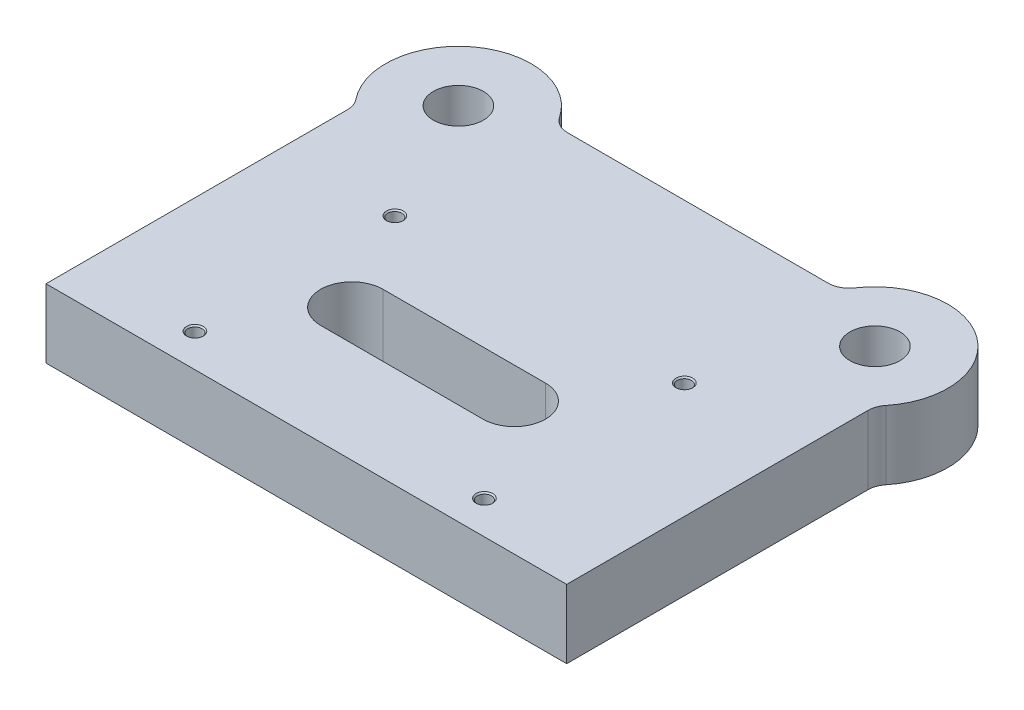
from build123d import *

# Parameters (mm, degrees)
SKETCH1_R                   = 12
BOSS_EXTRUDE1_DEPTH         = 33
FILLET1_R                   = 10
M8_TAPPED_HOLE1_D           = 6.8
M8_TAPPED_HOLE1_DEPTH       = 33
M8_TAPPED_HOLE1_CSINK_D     = 8.05
M8_TAPPED_HOLE1_CSINK_ANGLE = 90
CUT_EXTRUDE1_REACH          = 35


with BuildPart() as part:
    # Sketch1 → Boss-Extrude1 (new body)
    with BuildSketch(Plane(origin=(0, 0, 0), x_dir=(1, 0, 0), z_dir=(0, 1, 0))):
        with BuildLine():
            Line((125, 0), (-125, 0))
            Line((-125, 0), (-125, 148.505102572))
            ThreePointArc((-125, 148.505102572), (-120.023162168, 201.706671295), (-68.377223398, 188))
            Line((-68.377223398, 188), (68.377223398, 188))
            ThreePointArc((68.377223398, 188), (120.023162168, 201.706671295), (125, 148.505102572))
            Line((125, 148.505102572), (125, 0))
        make_face()
        with Locations((-100, 173)):
            Circle(SKETCH1_R, mode=Mode.SUBTRACT)
        with Locations((100, 173)):
            Circle(SKETCH1_R, mode=Mode.SUBTRACT)
    extrude(amount=BOSS_EXTRUDE1_DEPTH)

    # Fillet1
    fillet1_edges = [part.edges().sort_by_distance(p)[0] for p in [
        (-125, 16.5, -148.505102572),
        (-68.377223398, 16.5, -188),
        (68.377223398, 16.5, -188),
        (125, 16.5, -148.505102572),
    ]]
    fillet(fillet1_edges, radius=FILLET1_R)

    # M8 Tapped Hole1
    with Locations(Plane(origin=(0, 33, 0), x_dir=(1, 0, 0), z_dir=(0, 1, 0))):
        with Locations((-69.5, 112), (69.5, 112), (69.5, 16), (-69.5, 16)):
            CounterSinkHole(M8_TAPPED_HOLE1_D / 2, M8_TAPPED_HOLE1_CSINK_D / 2, depth=M8_TAPPED_HOLE1_DEPTH, counter_sink_angle=M8_TAPPED_HOLE1_CSINK_ANGLE)

    # Sketch4 → Cut-Extrude1 (cut, up to next)
    with BuildSketch(Plane(origin=(0, 33, 0), x_dir=(1, 0, 0), z_dir=(0, 1, 0)), mode=Mode.PRIVATE) as cut_extrude1_sk1:
        with BuildLine():
            Line((-41.773055434, 78.602374467), (36.226944566, 78.602374467))
            ThreePointArc((36.226944566, 78.602374467), (51.226944566, 63.602374467), (36.226944566, 48.602374467))
            Line((36.226944566, 48.602374467), (-41.773055434, 48.602374467))
            ThreePointArc((-41.773055434, 48.602374467), (-56.773055434, 63.602374467), (-41.773055434, 78.602374467))
        make_face()
    cut_extrude1_tool1 = extrude(cut_extrude1_sk1.sketch, amount=-CUT_EXTRUDE1_REACH, mode=Mode.PRIVATE) & part.part
    add(cut_extrude1_tool1.solids().sort_by_distance((-2.773055, 33, -63.602374))[0], mode=Mode.SUBTRACT)


solid = part.part
